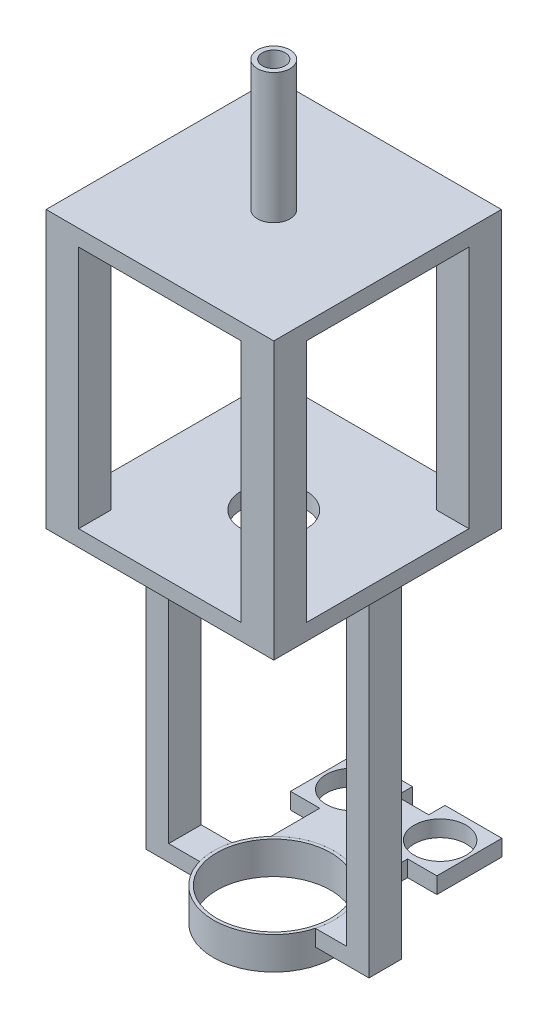
from build123d import *

# Parameters (mm, degrees)
CONNECTOR_SLEEVE_DEPTH      = 5
CONNECTOR_SLEEVE_DEPTH_BACK = 5
SKETCH2_10_R                = 8
SKETCH2_10_W                = 6.970509831
SKETCH2_10_H                = 10
SENSOR_HOLDER_DEPTH         = 5
SKETCH2_18_W                = 6.970509831
SKETCH2_18_H                = 10
BOSS_EXTRUDE1_DEPTH         = 100
SKETCH4_W                   = 70
SKETCH4_H                   = 70
SKETCH4_R                   = 10
MOTOR_ENCLOSURE_DEPTH       = 5
SKETCH6_W                   = 10
SKETCH6_H                   = 10
MOTOR_ENCLOSURE_2_DEPTH     = 75
SKETCH7_W                   = 70
SKETCH7_H                   = 70
MOTOR_ENCLOSURE_3_DEPTH     = 5
SKETCH8_R                   = 5
BOSS_EXTRUDE5_DEPTH         = 40
SKETCH26_R                  = 3.5
CUT_EXTRUDE1_DEPTH          = 45


with BuildPart() as part:
    # Sketch2 → Connector sleeve (new body, two sides)
    with BuildSketch(Plane(origin=(0, 0, 0), x_dir=(1, 0, 0), z_dir=(0, 1, 0))) as connector_sleeve_sk:
        with BuildLine():
            Line((-16.770509831, -5), (-17.811513131, -5))
            ThreePointArc((-17.811513131, -5), (0, -18.5), (17.811513131, -5))
            Line((17.811513131, -5), (16.770509831, -5))
            ThreePointArc((16.770509831, -5), (0, -17.5), (-16.770509831, -5))
        make_face()
        with BuildLine():
            ThreePointArc((-13.5, 12.649110641), (-16.116139024, 9.084055425), (-17.811513131, 5))
            Line((-17.811513131, 5), (-16.770509831, 5))
            ThreePointArc((-16.770509831, 5), (0, 17.5), (16.770509831, 5))
            Line((16.770509831, 5), (17.811513131, 5))
            ThreePointArc((17.811513131, 5), (16.116139024, 9.084055425), (13.5, 12.649110641))
            ThreePointArc((13.5, 12.649110641), (0, 18.5), (-13.5, 12.649110641))
        make_face()
        with BuildLine():
            Line((17.811513131, 5), (16.770509831, 5))
            ThreePointArc((16.770509831, 5), (17.316667145, 2.526467688), (17.5, 0))
            ThreePointArc((17.5, 0), (17.316667145, -2.526467688), (16.770509831, -5))
            Line((16.770509831, -5), (17.811513131, -5))
            ThreePointArc((17.811513131, -5), (18.327070046, -2.523589416), (18.5, 0))
            ThreePointArc((18.5, 0), (18.327070046, 2.523589416), (17.811513131, 5))
        make_face()
        with BuildLine():
            Line((-16.770509831, 5), (-17.811513131, 5))
            ThreePointArc((-17.811513131, 5), (-18.5, 0), (-17.811513131, -5))
            Line((-17.811513131, -5), (-16.770509831, -5))
            ThreePointArc((-16.770509831, -5), (-17.5, 0), (-16.770509831, 5))
        make_face()
    extrude(amount=CONNECTOR_SLEEVE_DEPTH)
    extrude(connector_sleeve_sk.sketch, amount=-CONNECTOR_SLEEVE_DEPTH_BACK)


with BuildPart() as body_2:
    # Sketch2_10 → Sensor holder (new body)
    with BuildSketch(Plane(origin=(0, 0, 0), x_dir=(1, 0, 0), z_dir=(0, 1, 0))):
        Polygon((5, 42.649110641), (5, 47.649110641), (22.5, 47.649110641), (22.5, 27.649110641), (0, 27.649110641), (-22.5, 27.649110641), (-22.5, 47.649110641), (-5, 47.649110641), (-5, 42.649110641), align=None)
        with Locations((13.5, 37.649110641)):
            Circle(SKETCH2_10_R, mode=Mode.SUBTRACT)
        with Locations((-13.5, 37.649110641)):
            Circle(SKETCH2_10_R, mode=Mode.SUBTRACT)
        with BuildLine():
            Line((-13.5, 27.649110641), (-13.5, 12.649110641))
            ThreePointArc((-13.5, 12.649110641), (0, 18.5), (13.5, 12.649110641))
            Line((13.5, 12.649110641), (13.5, 27.649110641))
            Line((13.5, 27.649110641), (0, 27.649110641))
            Line((0, 27.649110641), (-13.5, 27.649110641))
        make_face()
        with BuildLine():
            Line((-17.811513131, 5), (-27.3, 5))
            Line((-27.3, 5), (-27.3, -5))
            Line((-27.3, -5), (-17.811513131, -5))
            ThreePointArc((-17.811513131, -5), (-18.5, 0), (-17.811513131, 5))
        make_face()
        with Locations((-30.785254916, 0)):
            Rectangle(SKETCH2_10_W, SKETCH2_10_H)
        with BuildLine():
            ThreePointArc((18.5, 0), (18.327070046, -2.523589416), (17.811513131, -5))
            Line((17.811513131, -5), (27.3, -5))
            Line((27.3, -5), (27.3, 5))
            Line((27.3, 5), (17.811513131, 5))
            ThreePointArc((17.811513131, 5), (18.327070046, 2.523589416), (18.5, 0))
        make_face()
        with Locations((30.785254916, 0)):
            Rectangle(SKETCH2_10_W, SKETCH2_10_H)
    extrude(amount=SENSOR_HOLDER_DEPTH)

    # Sketch2_18 → Boss-Extrude1 (add)
    with BuildSketch(Plane(origin=(0, 0, 0), x_dir=(1, 0, 0), z_dir=(0, 1, 0))):
        with Locations((-30.785254916, 0)):
            Rectangle(SKETCH2_18_W, SKETCH2_18_H)
        with Locations((30.785254916, 0)):
            Rectangle(SKETCH2_18_W, SKETCH2_18_H)
    extrude(amount=BOSS_EXTRUDE1_DEPTH)

    # Sketch4 → Motor enclosure (add)
    with BuildSketch(Plane(origin=(0, 100, 0), x_dir=(1, 0, 0), z_dir=(0, 1, 0))):
        Rectangle(SKETCH4_W, SKETCH4_H)
        Circle(SKETCH4_R, mode=Mode.SUBTRACT)
    extrude(amount=MOTOR_ENCLOSURE_DEPTH)

    # Sketch6 → Motor enclosure 2 (add)
    with BuildSketch(Plane(origin=(0, 105, 0), x_dir=(1, 0, 0), z_dir=(0, 1, 0))):
        with Locations((-30, 30)):
            Rectangle(SKETCH6_W, SKETCH6_H)
        with Locations((30, 30)):
            Rectangle(SKETCH6_W, SKETCH6_H)
        with Locations((30, -30)):
            Rectangle(SKETCH6_W, SKETCH6_H)
        with Locations((-30, -30)):
            Rectangle(SKETCH6_W, SKETCH6_H)
    extrude(amount=MOTOR_ENCLOSURE_2_DEPTH)

    # Sketch7 → Motor enclosure 3 (add)
    with BuildSketch(Plane(origin=(0, 180, 0), x_dir=(1, 0, 0), z_dir=(0, 1, 0))):
        Rectangle(SKETCH7_W, SKETCH7_H)
    extrude(amount=MOTOR_ENCLOSURE_3_DEPTH)

    # Sketch8 → Boss-Extrude5 (add)
    with BuildSketch(Plane(origin=(0, 185, 0), x_dir=(1, 0, 0), z_dir=(0, 1, 0))):
        Circle(SKETCH8_R)
    extrude(amount=BOSS_EXTRUDE5_DEPTH)

    # Sketch26 → Cut-Extrude1 (cut)
    with BuildSketch(Plane(origin=(0, 225, 0), x_dir=(1, 0, 0), z_dir=(0, 1, 0))):
        Circle(SKETCH26_R)
    extrude(amount=-CUT_EXTRUDE1_DEPTH, mode=Mode.SUBTRACT)


solid = Compound([part.part, body_2.part])
